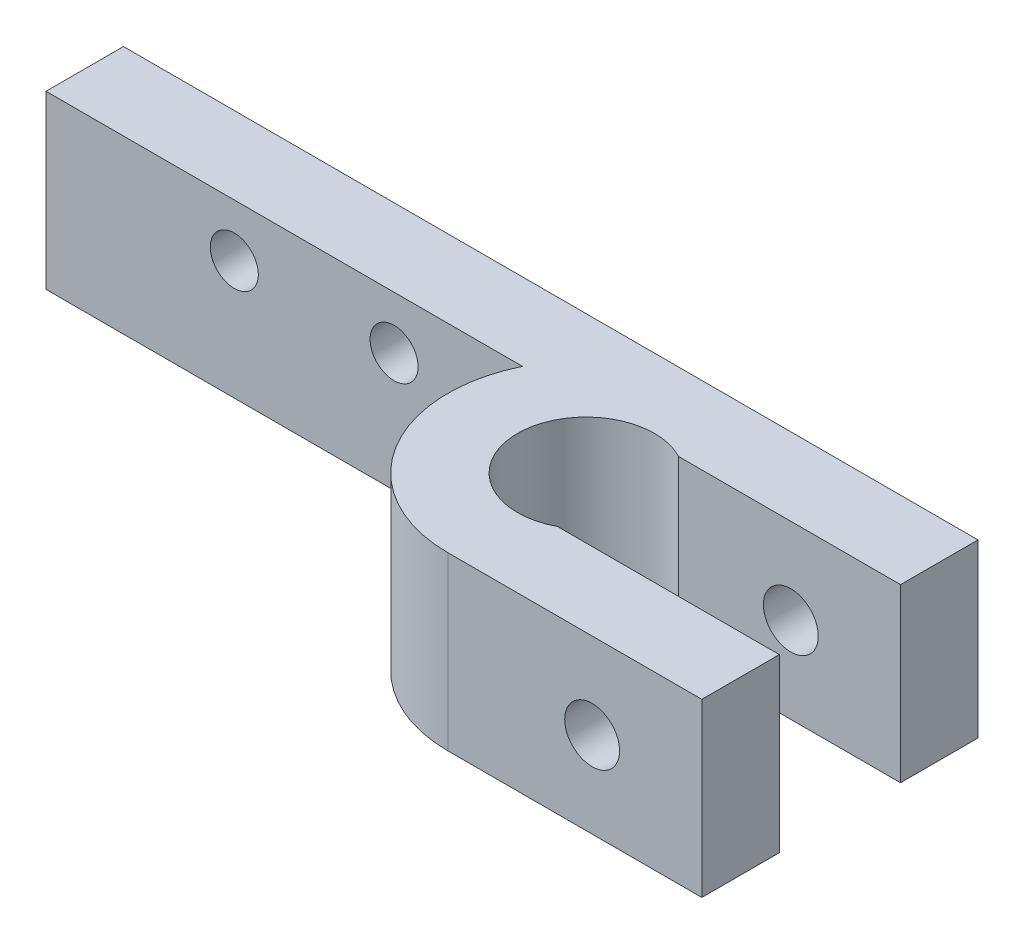
from build123d import *

# Parameters (mm, degrees)
BOSS_EXTRUDE1_DEPTH = 10.01
SKETCH2_R           = 4
CUT_EXTRUDE1_DEPTH  = 11.01
SKETCH3_R           = 1.6
CUT_EXTRUDE2_DEPTH  = 17.11
CUT_EXTRUDE3_REACH  = 18.11
SKETCH5_R           = 1.4


with BuildPart() as part:
    # Sketch1 → Boss-Extrude1 (new body)
    with BuildSketch(Plane(origin=(0, 0, 0), x_dir=(1, 0, 0), z_dir=(0, 1, 0))):
        with BuildLine():
            Line((-49.85, 0), (0, 0))
            Line((0, 0), (0, -4.52))
            Line((0, -4.52), (-14.815, -4.52))
            ThreePointArc((-14.815, -4.52), (-18.35, -8.055), (-14.815, -11.59))
            Line((-14.815, -11.59), (0, -11.59))
            Line((0, -11.59), (0, -16.11))
            Line((0, -16.11), (-14.815, -16.11))
            ThreePointArc((-14.815, -16.11), (-21.647183033, -12.32164974), (-22.052872616, -4.52))
            Line((-22.052872616, -4.52), (-49.85, -4.52))
            Line((-49.85, -4.52), (-49.85, 0))
        make_face()
    extrude(amount=BOSS_EXTRUDE1_DEPTH)

    # Sketch2 → Cut-Extrude1 (cut, through all)
    with BuildSketch(Plane(origin=(0, 10.01, 0), x_dir=(1, 0, 0), z_dir=(0, 1, 0))):
        with Locations((-14.815, -8.055)):
            Circle(SKETCH2_R)
    extrude(amount=-CUT_EXTRUDE1_DEPTH, mode=Mode.SUBTRACT)

    # Sketch3 → Cut-Extrude2 (cut, through all)
    with BuildSketch(Plane(origin=(0, 0, 0), x_dir=(-1, 0, 0), z_dir=(0, 0, -1))):
        with Locations((6.39994888, 5.005)):
            Circle(SKETCH3_R)
    extrude(amount=-CUT_EXTRUDE2_DEPTH, mode=Mode.SUBTRACT)

    # Sketch5 → Cut-Extrude3 (cut, up to next)
    with BuildSketch(Plane(origin=(0, 0, 0), x_dir=(-1, 0, 0), z_dir=(0, 0, -1)), mode=Mode.PRIVATE) as cut_extrude3_sk1:
        with Locations((29.545, 6.94)):
            Circle(SKETCH5_R)
    cut_extrude3_tool1 = extrude(cut_extrude3_sk1.sketch, amount=-CUT_EXTRUDE3_REACH, mode=Mode.PRIVATE) & part.part
    add(cut_extrude3_tool1.solids().sort_by_distance((-29.545, 6.94, 0))[0], mode=Mode.SUBTRACT)
    # Sketch5 → Cut-Extrude3 (cut, up to next)
    with BuildSketch(Plane(origin=(0, 0, 0), x_dir=(-1, 0, 0), z_dir=(0, 0, -1)), mode=Mode.PRIVATE) as cut_extrude3_sk2:
        with Locations((38.865, 6.94)):
            Circle(SKETCH5_R)
    cut_extrude3_tool2 = extrude(cut_extrude3_sk2.sketch, amount=-CUT_EXTRUDE3_REACH, mode=Mode.PRIVATE) & part.part
    add(cut_extrude3_tool2.solids().sort_by_distance((-38.865, 6.94, 0))[0], mode=Mode.SUBTRACT)


solid = part.part
